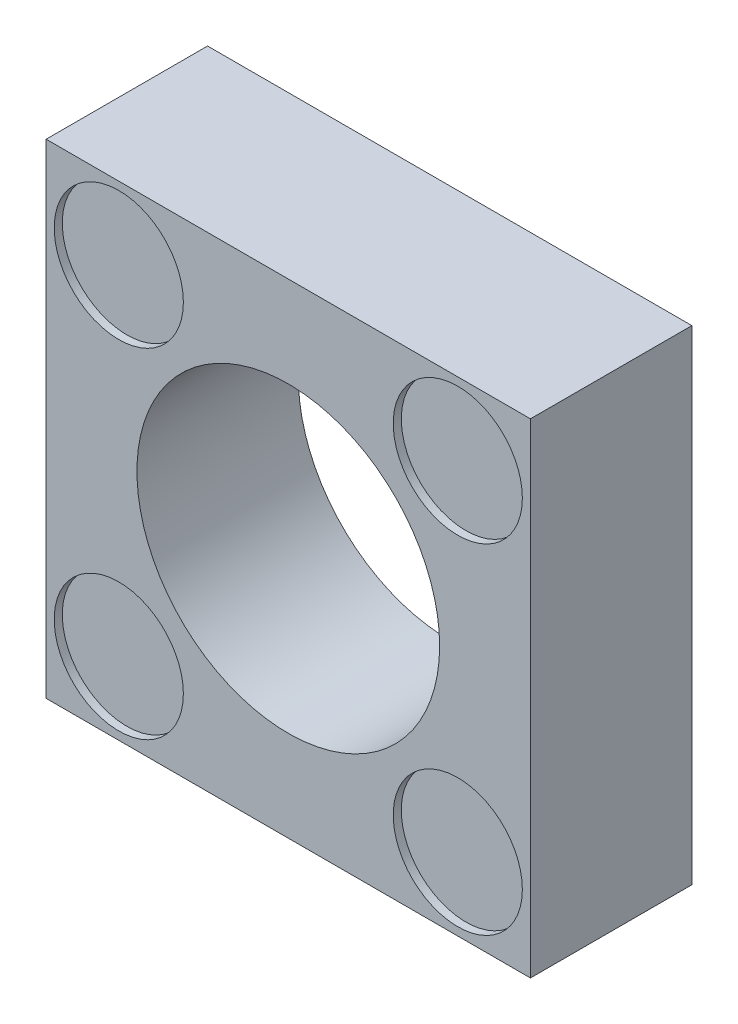
from build123d import *

# Parameters (mm, degrees)
CROQUIS1_W              = 600
CROQUIS1_H              = 600
CROQUIS1_R              = 187.5
SALIENTE_EXTRUIR1_DEPTH = 200
CROQUIS2_R              = 80
CORTAR_EXTRUIR1_DEPTH   = 10


with BuildPart() as part:
    # Croquis1 → Saliente-Extruir1 (new body)
    with BuildSketch(Plane.XY):
        Rectangle(CROQUIS1_W, CROQUIS1_H)
        Circle(CROQUIS1_R, mode=Mode.SUBTRACT)
    extrude(amount=SALIENTE_EXTRUIR1_DEPTH)

    # Croquis2 → Cortar-Extruir1 (cut)
    with BuildSketch(Plane.XY.offset(200)):
        with Locations((-210, 210)):
            Circle(CROQUIS2_R)
        with Locations((210, 210)):
            Circle(CROQUIS2_R)
        with Locations((210, -210)):
            Circle(CROQUIS2_R)
        with Locations((-210, -210)):
            Circle(CROQUIS2_R)
    extrude(amount=-CORTAR_EXTRUIR1_DEPTH, mode=Mode.SUBTRACT)


solid = part.part
